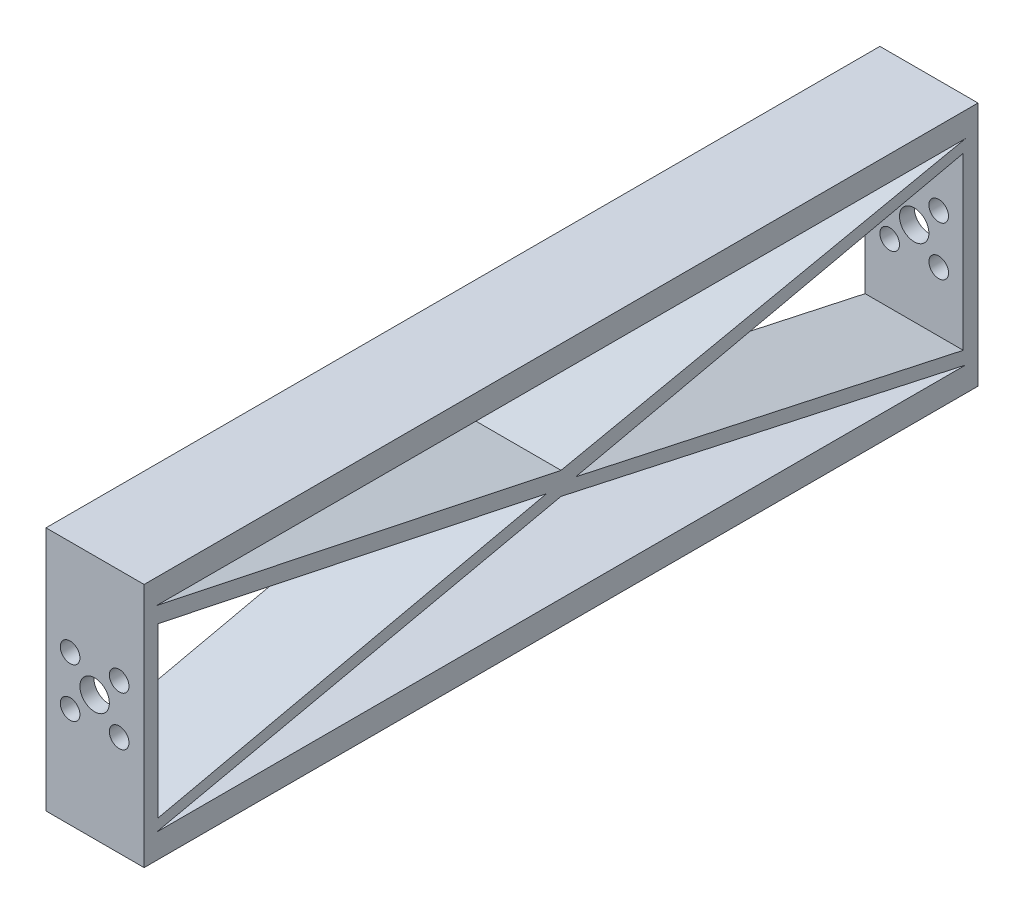
from build123d import *

# Parameters (mm, degrees)
SKETCH4_W           = 170
SKETCH4_H           = 50
BOSS_EXTRUDE1_DEPTH = 20
CUT_EXTRUDE5_DEPTH  = 20
CUT_EXTRUDE6_DEPTH  = 20
SKETCH7_R           = 3
SKETCH7_R_2         = 2
CUT_EXTRUDE7_DEPTH  = 5
SKETCH8_R           = 3
SKETCH8_R_2         = 2
CUT_EXTRUDE8_DEPTH  = 5


with BuildPart() as part:
    # Sketch4 → Boss-Extrude1 (new body)
    with BuildSketch(Plane(origin=(0, 0, 0), x_dir=(0, 0, -1), z_dir=(1, 0, 0))):
        Rectangle(SKETCH4_W, SKETCH4_H)
    extrude(amount=BOSS_EXTRUDE1_DEPTH)

    # Sketch5 → Cut-Extrude5 (cut)
    with BuildSketch(Plane.ZY):
        Polygon((-82.5, 20), (82.5, 20), (0, 2.648640731), align=None)
        Polygon((0, -1.957690975), (82.5, -20), (-82.5, -20), align=None)
    extrude(amount=-CUT_EXTRUDE5_DEPTH, mode=Mode.SUBTRACT)

    # Sketch6 → Cut-Extrude6 (cut)
    with BuildSketch(Plane.ZY):
        Polygon((-2.994115609, 0), (-81.99270438, 17.619218778), (-81.99270438, -17.158585608), align=None)
        Polygon((2.994115609, 0), (82.148587467, 16.647729441), (82.148587467, -17.653985706), align=None)
    extrude(amount=-CUT_EXTRUDE6_DEPTH, mode=Mode.SUBTRACT)

    # Sketch7 → Cut-Extrude7 (cut)
    with BuildSketch(Plane.XY.offset(85)):
        with Locations((9.915502372, 0.478984513)):
            Circle(SKETCH7_R)
        with Locations((4.915502372, -4.521015487)):
            Circle(SKETCH7_R_2)
        with Locations((14.915502372, -4.521015487)):
            Circle(SKETCH7_R_2)
        with Locations((14.915502372, 5.478984513)):
            Circle(SKETCH7_R_2)
        with Locations((4.915502372, 5.478984513)):
            Circle(SKETCH7_R_2)
    extrude(amount=-CUT_EXTRUDE7_DEPTH, mode=Mode.SUBTRACT)

    # Sketch8 → Cut-Extrude8 (cut)
    with BuildSketch(Plane(origin=(0, 0, -85), x_dir=(-1, 0, 0), z_dir=(0, 0, -1))):
        with Locations((-10, 0)):
            Circle(SKETCH8_R)
        with Locations((-15, 5)):
            Circle(SKETCH8_R_2)
        with Locations((-5, 5)):
            Circle(SKETCH8_R_2)
        with Locations((-5, -5)):
            Circle(SKETCH8_R_2)
        with Locations((-15, -5)):
            Circle(SKETCH8_R_2)
    extrude(amount=-CUT_EXTRUDE8_DEPTH, mode=Mode.SUBTRACT)


solid = part.part
